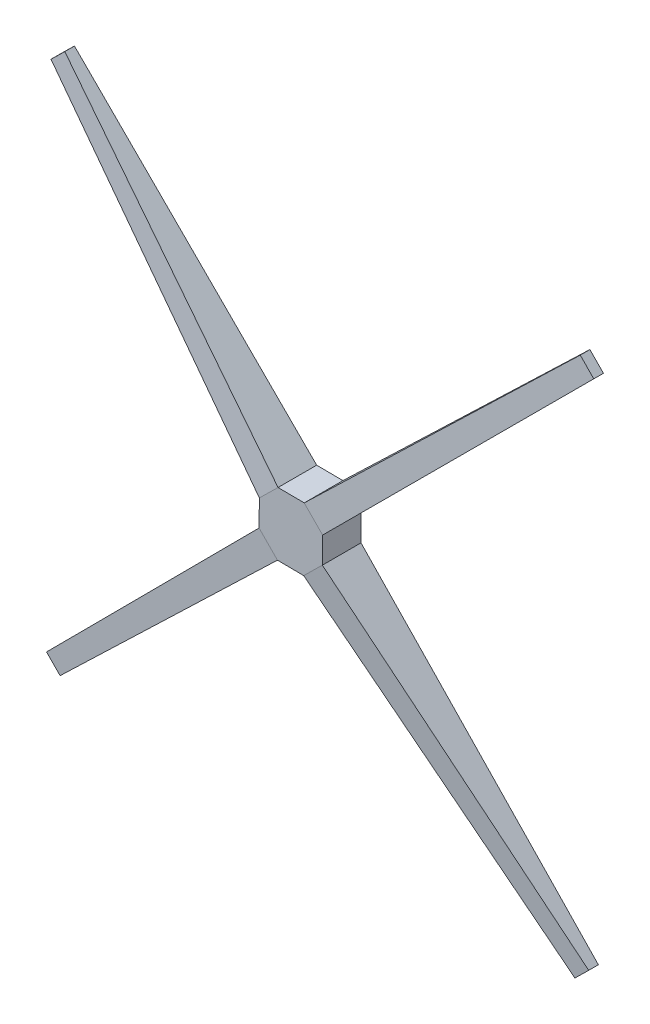
from build123d import *

# Parameters (mm, degrees)
BOSS_EXTRUDE1_DEPTH = 50.8
SKETCH5_W           = 50.8
SKETCH5_H           = 34.441508913
SKETCH8_W           = 12.7
SKETCH8_H           = 25.4
SKETCH11_W          = 50.8
SKETCH11_H          = 34.441508913
SKETCH10_W          = 12.7
SKETCH10_H          = 25.4
SKETCH12_W          = 34.441508912
SKETCH12_H          = 50.8
SKETCH13_W          = 25.4
SKETCH13_H          = 12.7
SKETCH14_W          = 34.441508912
SKETCH14_H          = 50.8
SKETCH15_W          = 25.4
SKETCH15_H          = 12.7


with BuildPart() as part:
    # Sketch3 → Boss-Extrude1 (new body)
    with BuildSketch(Plane.XY):
        Polygon((-583.133216143, 41.413481842), (-617.573251094, 41.732117626), (-642.151342876, 17.604644891), (-642.469978659, -16.83539006), (-618.342505925, -41.413481842), (-583.902470973, -41.732117626), (-559.324379192, -17.604644891), (-559.005743408, 16.83539006), align=None)
    extrude(amount=BOSS_EXTRUDE1_DEPTH)

    # Sketch5 → Loft1 section 0
    with BuildSketch(Plane(origin=(-335.594803105, -329.44194911, 0), x_dir=(0, 0, 1), z_dir=(-0.713618322, -0.700534718, 0))):
        with Locations((25.4, 420.837728092)):
            Rectangle(SKETCH5_W, SKETCH5_H)
    # Sketch8 → Loft1 section 1
    with BuildSketch(Plane(origin=(-656.72304774, -644.682572171, 0), x_dir=(0, 0, 1), z_dir=(-0.713618322, -0.700534718, 0))):
        with Locations((6.35, 420.201309854)):
            Rectangle(SKETCH8_W, SKETCH8_H)
    loft()

    # Sketch11 → Loft2 section 0
    with BuildSketch(Plane(origin=(-276.258040589, -271.193077208, 0), x_dir=(0, 0, -1), z_dir=(0.713618322, 0.700534718, 0))):
        with Locations((-25.4, 420.837728092)):
            Rectangle(SKETCH11_W, SKETCH11_H)
    # Sketch10 → Loft2 section 1
    with BuildSketch(Plane(origin=(44.870204046, 44.047545853, 0), x_dir=(0, 0, -1), z_dir=(0.713618322, 0.700534718, 0))):
        with Locations((-6.35, 420.201309854)):
            Rectangle(SKETCH10_W, SKETCH10_H)
    loft()

    # Sketch12 → Loft3 section 0
    with BuildSketch(Plane(origin=(-265.687003236, 270.649131901, 0), x_dir=(-0.713618322, -0.700534718, 0), z_dir=(0.700534718, -0.713618322, 0))):
        with Locations((428.697544073, -25.4)):
            Rectangle(SKETCH12_W, SKETCH12_H)
    # Sketch13 → Loft3 section 1
    with BuildSketch(Plane(origin=(49.553619825, -50.479112734, 0), x_dir=(-0.713618322, -0.700534718, 0), z_dir=(0.700534718, -0.713618322, 0))):
        with Locations((428.656835586, -6.35)):
            Rectangle(SKETCH13_W, SKETCH13_H)
    loft()

    # Sketch14 → Loft4 section 0
    with BuildSketch(Plane(origin=(-323.935875138, 329.985894417, 0), x_dir=(0.713618322, 0.700534718, 0), z_dir=(-0.700534718, 0.713618322, 0))):
        with Locations((-428.697544073, -25.4)):
            Rectangle(SKETCH14_W, SKETCH14_H)
    # Sketch15 → Loft4 section 1
    with BuildSketch(Plane(origin=(-639.176498199, 651.114139052, 0), x_dir=(0.713618322, 0.700534718, 0), z_dir=(-0.700534718, 0.713618322, 0))):
        with Locations((-428.656835586, -6.35)):
            Rectangle(SKETCH15_W, SKETCH15_H)
    loft()


solid = part.part
